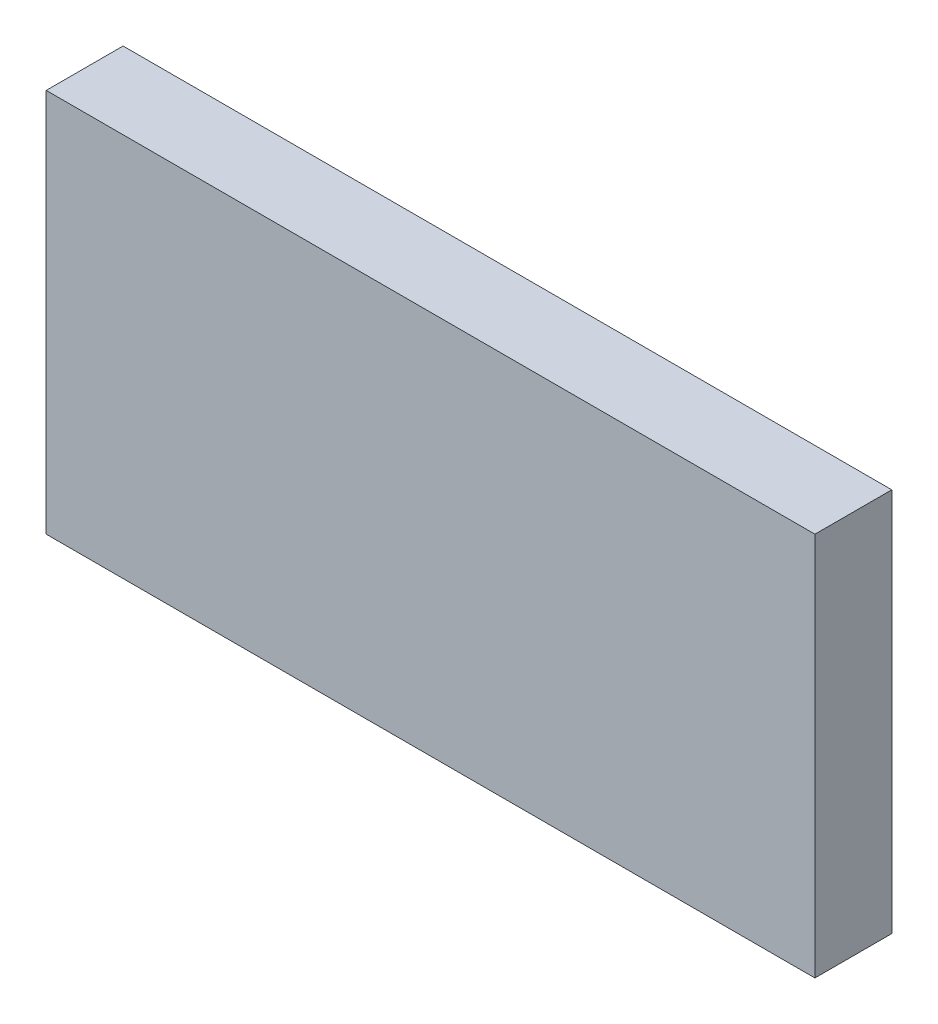
from build123d import *

# Parameters (mm, degrees)
SKETCH1_W           = 100
SKETCH1_H           = 50
BOSS_EXTRUDE1_DEPTH = 10


with BuildPart() as part:
    # Sketch1 → Boss-Extrude1 (new body)
    with BuildSketch(Plane.XY):
        with Locations((50, -25)):
            Rectangle(SKETCH1_W, SKETCH1_H)
    extrude(amount=BOSS_EXTRUDE1_DEPTH)


solid = part.part
